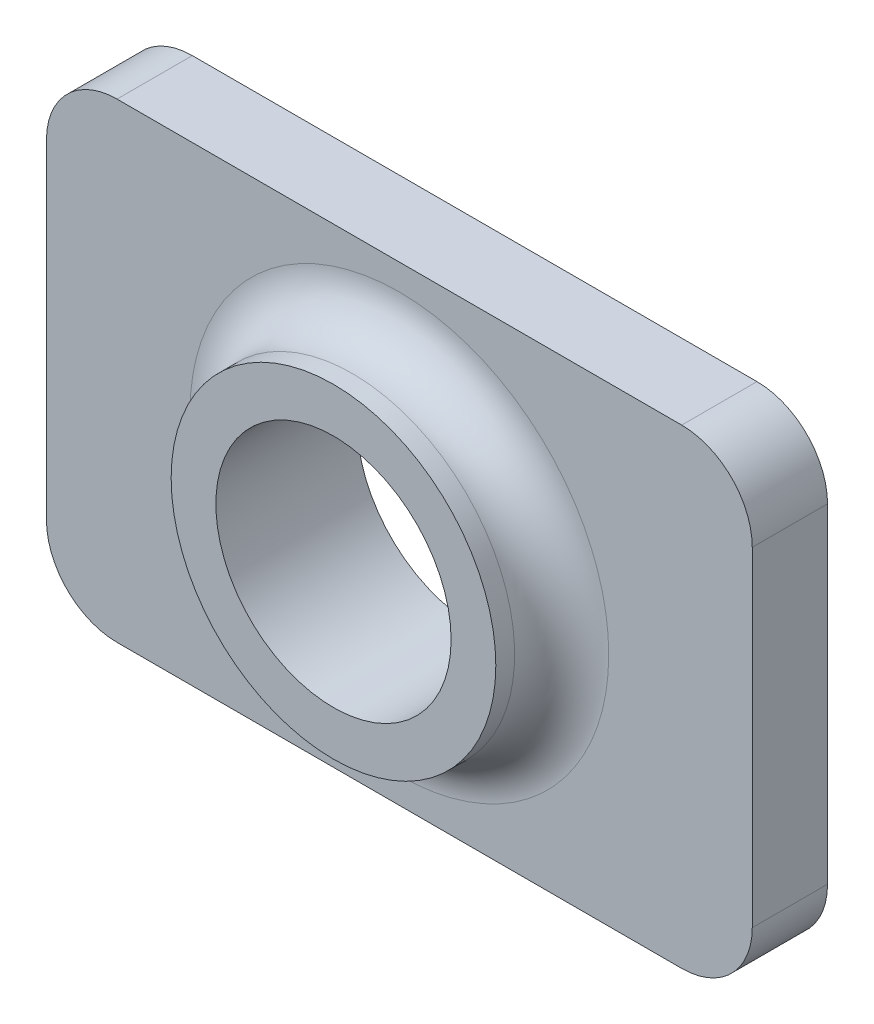
from build123d import *

# Parameters (mm, degrees)
SKETCH1_W               = 15
SKETCH1_H               = 10
BOSS_EXTRUDE1_DEPTH     = 1.6
FILLET1_R               = 1.5
SKETCH2_R               = 3.45
BOSS_EXTRUDE2_DEPTH     = 1.4
CUT_EXTRUDE1_DEPTH      = 1.4
CUT_EXTRUDE1_DEPTH_BACK = 1.6
SKETCH2_3_R             = 2.5
FILLET2_R               = 1


with BuildPart() as part:
    # Sketch1 → Boss-Extrude1 (new body)
    with BuildSketch(Plane.XY):
        with Locations((7.5, 5)):
            Rectangle(SKETCH1_W, SKETCH1_H)
    extrude(amount=BOSS_EXTRUDE1_DEPTH)

    # Fillet1
    fillet1_edges = [part.edges().sort_by_distance(p)[0] for p in [
        (15, 0, 0.8),
        (0, 0, 0.8),
        (0, 10, 0.8),
        (15, 10, 0.8),
    ]]
    fillet(fillet1_edges, radius=FILLET1_R)

    # Sketch2 → Boss-Extrude2 (add)
    with BuildSketch(Plane.XY.offset(1.6)):
        with Locations((7.5, 5)):
            Circle(SKETCH2_R)
    extrude(amount=BOSS_EXTRUDE2_DEPTH)

    # Sketch2_3 → Cut-Extrude1 (cut, two sides: drawn at the far end of the back side and taken through both)
    with BuildSketch(Plane.XY.offset(1.6).offset(-CUT_EXTRUDE1_DEPTH_BACK)):
        with Locations((7.5, 5)):
            Circle(SKETCH2_3_R)
    extrude(amount=CUT_EXTRUDE1_DEPTH + CUT_EXTRUDE1_DEPTH_BACK, mode=Mode.SUBTRACT)

    # Fillet2
    fillet2_edges = [part.edges().sort_by_distance(p)[0] for p in [
        (4.05, 5, 1.6),
    ]]
    fillet(fillet2_edges, radius=FILLET2_R)


solid = part.part
